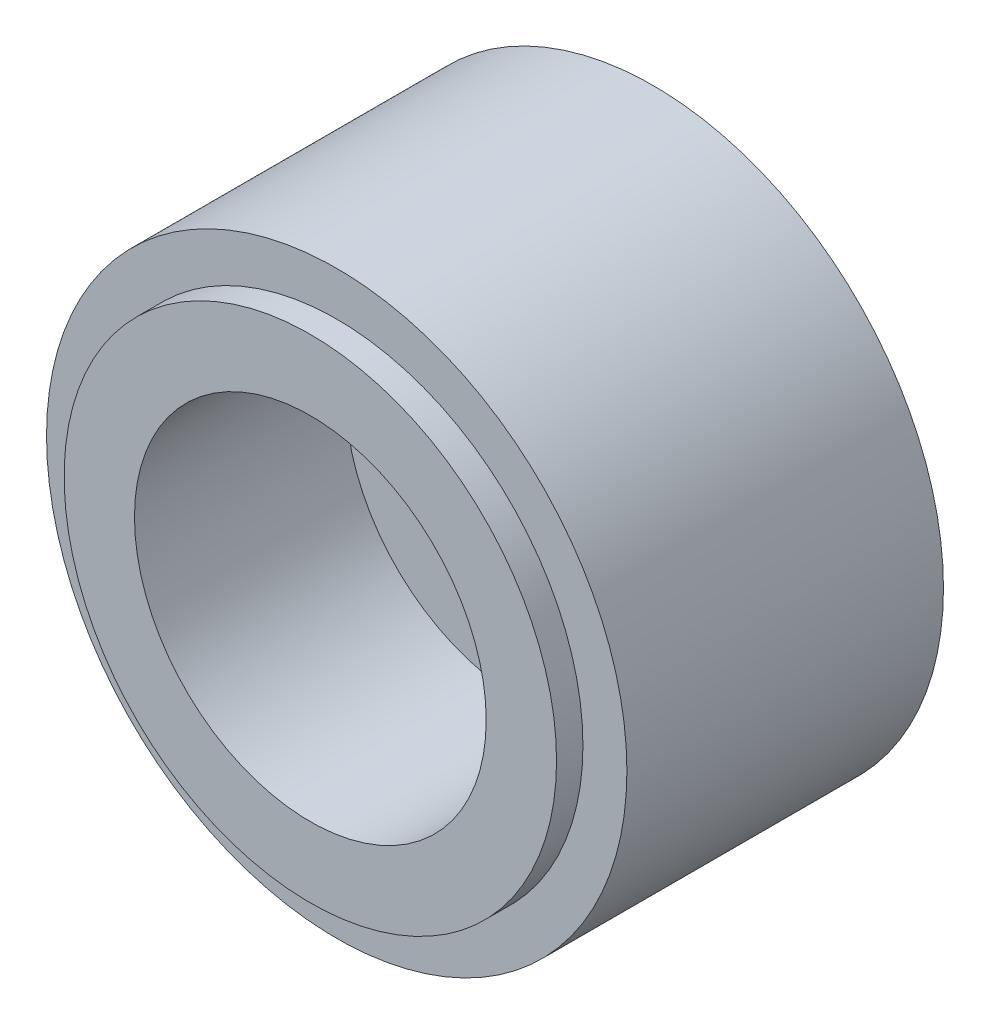
from build123d import *

# Parameters (mm, degrees)
SKETCH1_R           = 14
SKETCH1_R_2         = 1.5
BOSS_EXTRUDE1_DEPTH = 1.5
SKETCH2_R           = 10.5
SKETCH2_R_2         = 1.5
BOSS_EXTRUDE2_DEPTH = 18
SKETCH3_R           = 14
SKETCH3_R_2         = 1.5
BOSS_EXTRUDE3_DEPTH = 1.5
SKETCH4_R           = 10
CUT_EXTRUDE1_DEPTH  = 12
SKETCH5_R           = 16.5
SKETCH5_R_2         = 10.5
BOSS_EXTRUDE4_DEPTH = 18


with BuildPart() as part:
    # Sketch1 → Boss-Extrude1 (new body)
    with BuildSketch(Plane.XY):
        Circle(SKETCH1_R)
        Circle(SKETCH1_R_2, mode=Mode.SUBTRACT)
    extrude(amount=BOSS_EXTRUDE1_DEPTH)

    # Sketch2 → Boss-Extrude2 (add)
    with BuildSketch(Plane.XY.offset(1.5)):
        Circle(SKETCH2_R)
        Circle(SKETCH2_R_2, mode=Mode.SUBTRACT)
    extrude(amount=BOSS_EXTRUDE2_DEPTH)

    # Sketch3 → Boss-Extrude3 (add)
    with BuildSketch(Plane.XY.offset(19.5)):
        Circle(SKETCH3_R)
        Circle(SKETCH3_R_2, mode=Mode.SUBTRACT)
    extrude(amount=BOSS_EXTRUDE3_DEPTH)

    # Sketch4 → Cut-Extrude1 (cut)
    with BuildSketch(Plane.XY.offset(21)):
        Circle(SKETCH4_R)
    extrude(amount=-CUT_EXTRUDE1_DEPTH, mode=Mode.SUBTRACT)

    # Sketch5 → Boss-Extrude4 (add)
    with BuildSketch(Plane.XY.offset(1.5)):
        Circle(SKETCH5_R)
        Circle(SKETCH5_R_2, mode=Mode.SUBTRACT)
    extrude(amount=BOSS_EXTRUDE4_DEPTH)


solid = part.part
